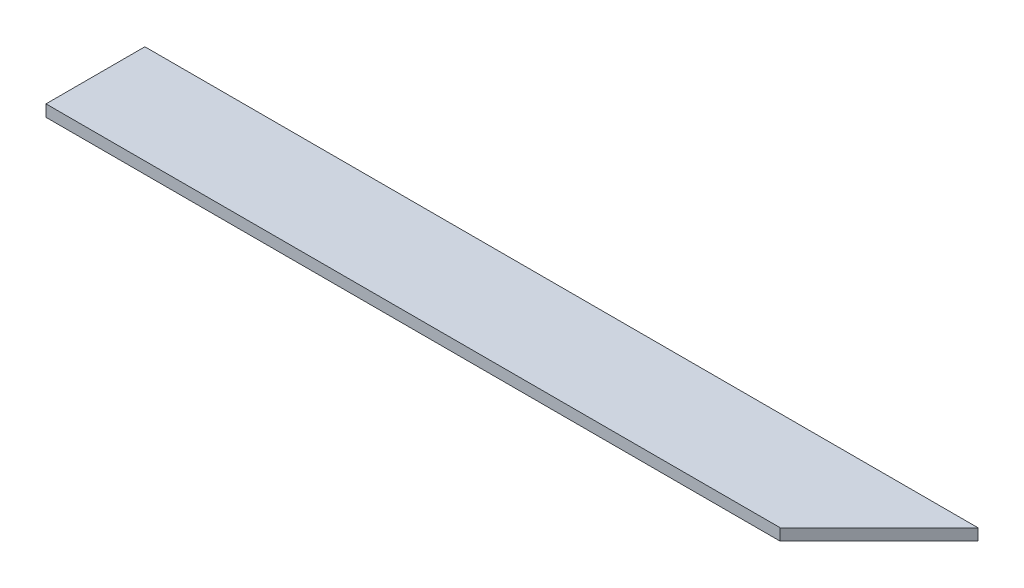
from build123d import *

# Parameters (mm, degrees)
SKETCH1_W           = 214
SKETCH1_H           = 25.4
BOSS_EXTRUDE1_DEPTH = 3
CUT_EXTRUDE2_DEPTH  = 10


with BuildPart() as part:
    # Sketch1 → Boss-Extrude1 (new body)
    with BuildSketch(Plane(origin=(0, 0, 0), x_dir=(1, 0, 0), z_dir=(0, 1, 0))):
        with Locations((7.129908201, 22.221008085)):
            Rectangle(SKETCH1_W, SKETCH1_H)
    extrude(amount=BOSS_EXTRUDE1_DEPTH)

    # Sketch2 → Cut-Extrude2 (cut)
    with BuildSketch(Plane(origin=(0, 3, 0), x_dir=(1, 0, 0), z_dir=(0, 1, 0))):
        Polygon((114.129908201, 34.921008085), (88.729908201, 9.521008085), (114.129908201, 9.521008085), align=None)
    extrude(amount=-CUT_EXTRUDE2_DEPTH, mode=Mode.SUBTRACT)


solid = part.part
